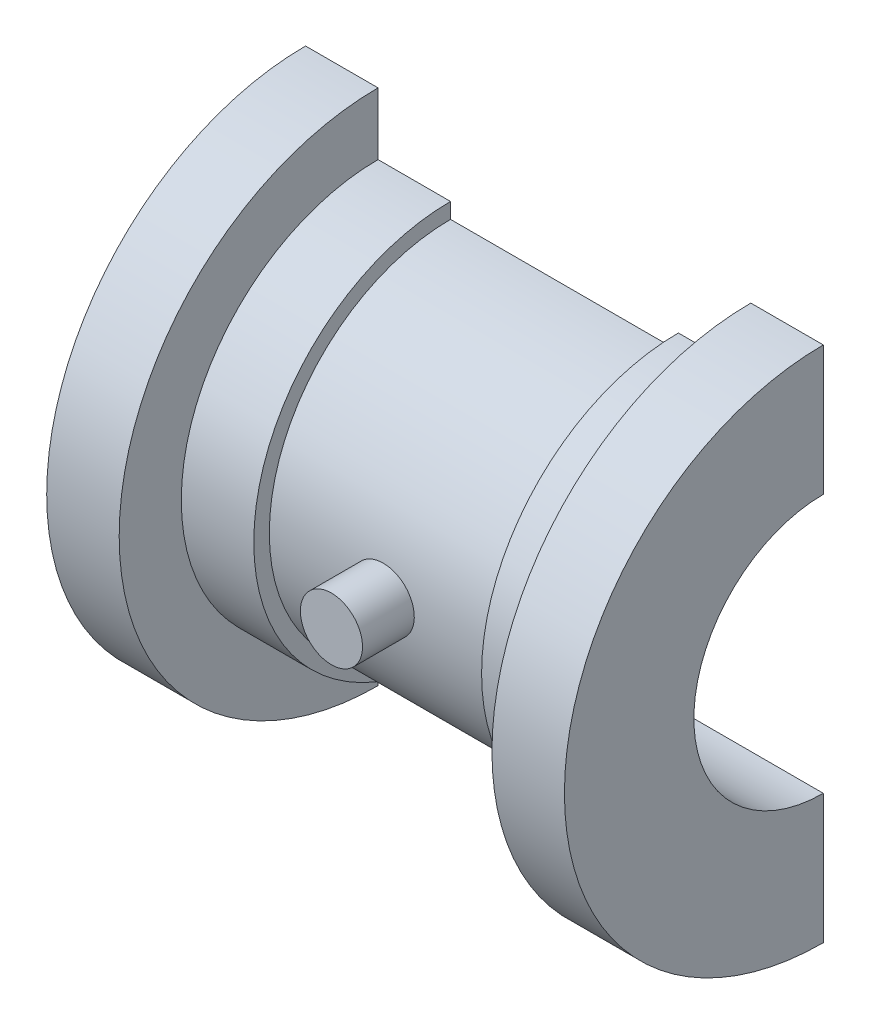
from build123d import *

# Parameters (mm, degrees)
REVOLVE1_ANGLE      = 180
CUT_EXTRUDE3_DEPTH  = 50
SKETCH4_R           = 3
BOSS_EXTRUDE1_DEPTH = 5


with BuildPart() as part:
    # Sketch1 → Revolve1 (revolve)
    with BuildSketch(Plane.XY):
        Polygon((25, 0), (-25, 0), (-25, 25), (-18, 25), (-18, 19), (-11, 19), (-11, 17.5), (11, 17.5), (11, 19), (18, 19), (18, 25), (25, 25), align=None)
    revolve(axis=Axis((-38.949360705, 0, 0), (1, 0, 0)), revolution_arc=REVOLVE1_ANGLE)

    # Sketch2 → Cut-Extrude3 (cut)
    with BuildSketch(Plane.ZY.offset(25)):
        with BuildLine():
            Line((0, 12.5), (0, -12.5))
            ThreePointArc((0, -12.5), (12.5, 0), (0, 12.5))
        make_face()
    extrude(amount=-CUT_EXTRUDE3_DEPTH, mode=Mode.SUBTRACT)


with BuildPart() as body_2:
    # Sketch4 → Boss-Extrude1 (new body)
    with BuildSketch(Plane(origin=(0, 0, 17.5), x_dir=(-1, 0, 0), z_dir=(0, 0, -1))):
        Circle(SKETCH4_R)
    extrude(amount=-BOSS_EXTRUDE1_DEPTH)


solid = Compound([part.part, body_2.part])
